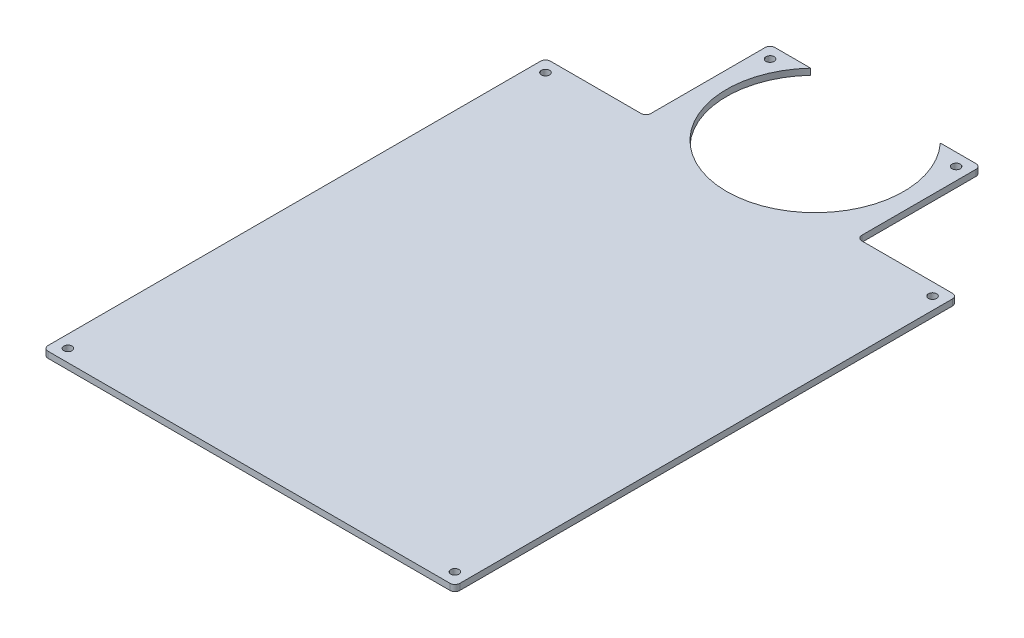
from build123d import *
from build123d.topology import SkipClean

# Parameters (mm, degrees)
SKETCH1_W           = 210.82
SKETCH1_H           = 257.175
BOSS_EXTRUDE1_DEPTH = 3.175
SKETCH3_R           = 2.0955
CUT_EXTRUDE1_DEPTH  = 3.175
SKETCH3_3_R         = 2.0955
BOSS_EXTRUDE2_DEPTH = 3.175
FILLET1_R           = 2.54


with BuildPart() as part:
    # Sketch1 → Boss-Extrude1 (new body)
    with BuildSketch(Plane(origin=(0, 0, 0), x_dir=(1, 0, 0), z_dir=(0, 1, 0))):
        with Locations((92.71, 115.8875)):
            Rectangle(SKETCH1_W, SKETCH1_H)
    extrude(amount=BOSS_EXTRUDE1_DEPTH)

    # Sketch3 → Cut-Extrude1 (cut)
    with BuildSketch(Plane(origin=(0, 3.175, 0), x_dir=(1, 0, 0), z_dir=(0, 1, 0))):
        with BuildLine():
            ThreePointArc((61.244272613, 244.475), (92.71, 231.775), (124.175727387, 244.475))
            Line((124.175727387, 244.475), (61.244272613, 244.475))
        make_face()
        with Locations((-6.35, 238.125)):
            Circle(SKETCH3_R)
        with Locations((191.77, 238.125)):
            Circle(SKETCH3_R)
        with Locations((191.77, -6.35)):
            Circle(SKETCH3_R)
        with Locations((-6.35, -6.35)):
            Circle(SKETCH3_R)
    extrude(amount=-CUT_EXTRUDE1_DEPTH, mode=Mode.SUBTRACT)

    # Sketch3_3 → Boss-Extrude2 (add)
    # profile 1 of 2: a face of its own
    with SkipClean():  # the faces are left unmerged after this step: merging them gives an invalid solid
        with BuildSketch(Plane(origin=(0, 3.175, 0), x_dir=(1, 0, 0), z_dir=(0, 1, 0))):
            with BuildLine():
                Line((38.735, 244.475), (61.244272613, 244.475))
                ThreePointArc((61.244272613, 244.475), (47.396783015, 275.871603687), (59.515843888, 307.975))
                Line((59.515843888, 307.975), (38.735, 307.975))
                Line((38.735, 307.975), (38.735, 244.475))
            make_face()
            with Locations((45.085, 301.625)):
                Circle(SKETCH3_3_R, mode=Mode.SUBTRACT)
        # profile 2 of 2: a face of its own
        with BuildSketch(Plane(origin=(0, 3.175, 0), x_dir=(1, 0, 0), z_dir=(0, 1, 0))):
            with BuildLine():
                Line((124.175727387, 244.475), (146.685, 244.475))
                Line((146.685, 244.475), (146.685, 307.975))
                Line((146.685, 307.975), (125.904156112, 307.975))
                ThreePointArc((125.904156112, 307.975), (138.023216985, 275.871603687), (124.175727387, 244.475))
            make_face()
            with Locations((140.335, 301.625)):
                Circle(SKETCH3_3_R, mode=Mode.SUBTRACT)
        extrude(amount=-BOSS_EXTRUDE2_DEPTH)

    # Fillet1
    fillet1_edges = [part.edges().sort_by_distance(p)[0] for p in [
        (38.735, 1.5875, -244.475),
        (146.685, 1.5875, -244.475),
        (38.735, 1.5875, -307.975),
        (146.685, 1.5875, -307.975),
        (-12.7, 1.5875, 12.7),
        (-12.7, 1.5875, -244.475),
        (198.12, 1.5875, -244.475),
        (198.12, 1.5875, 12.7),
    ]]
    fillet(fillet1_edges, radius=FILLET1_R)


solid = part.part
